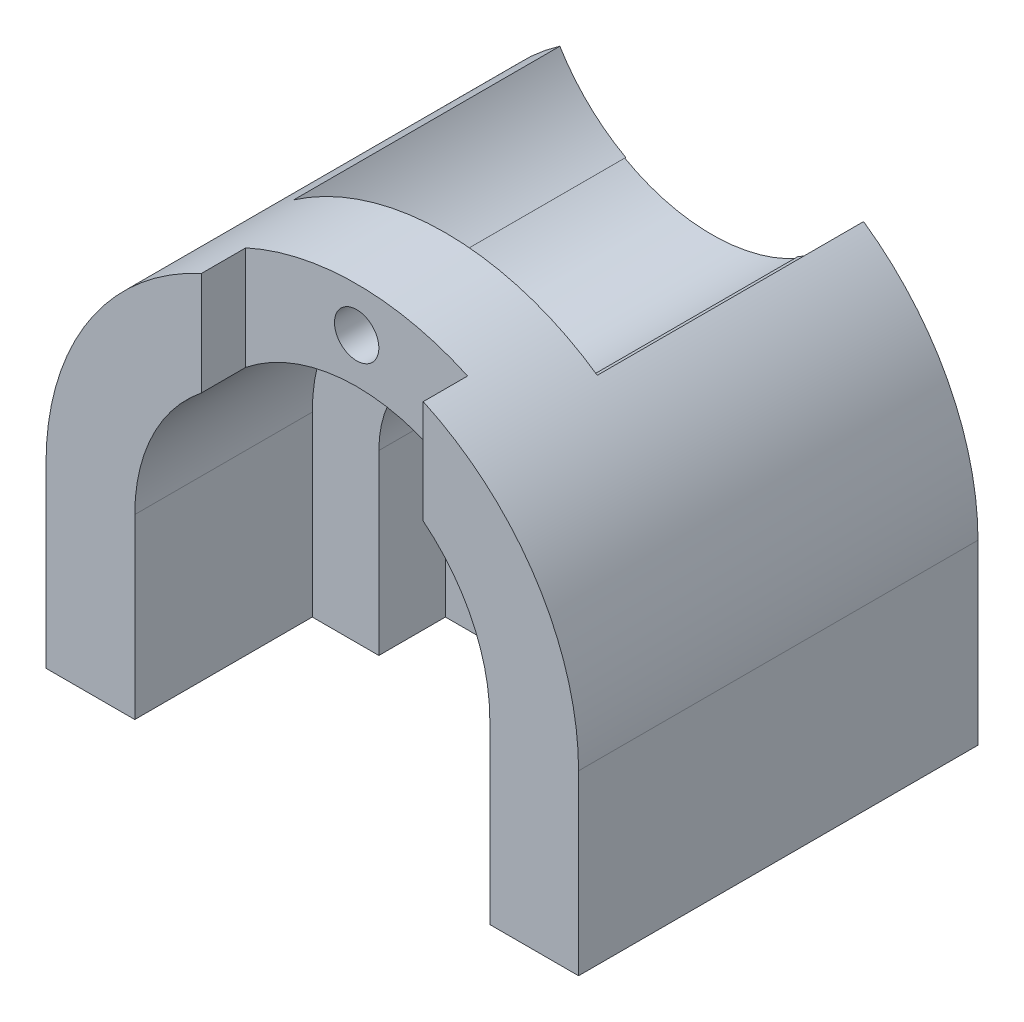
from build123d import *
from build123d.topology import SkipClean

# Parameters (mm, degrees)
BOSS_EXTRUDE1_DEPTH      = 90
SKETCH3_R                = 10
CUT_EXTRUDE2_DEPTH       = 90
SKETCH6_R                = 10
BOSS_EXTRUDE2_DEPTH      = 90
SKETCH7_R                = 5
CUT_EXTRUDE3_DEPTH       = 90
CUT_EXTRUDE4_START       = -60
CUT_EXTRUDE4_DEPTH       = 60
CUT_EXTRUDE5_START       = 60
CUT_EXTRUDE5_DEPTH       = 60
BOSS_EXTRUDE3_START      = 10
BOSS_EXTRUDE3_DEPTH      = 10
BOSS_EXTRUDE4_DEPTH      = 55
CUT_EXTRUDE6_DEPTH       = 40
CUT_EXTRUDE7_START       = -106
CUT_EXTRUDE7_DEPTH       = 106
SKETCH16_R               = 5
CUT_EXTRUDE8_DEPTH       = 106
CUT_EXTRUDE9_DEPTH       = 70
SKETCH18_R               = 5
BOSS_EXTRUDE6_DEPTH      = 15
CUT_EXTRUDE18_DEPTH      = 40
SKETCH22_W               = 40
SKETCH22_H               = 41.844000914
CUT_EXTRUDE19_DEPTH      = 20
SKETCH23_W               = 40
SKETCH23_H               = 40.367693543
CUT_EXTRUDE20_DEPTH      = 20
SKETCH25_R               = 25
BOSS_EXTRUDE7_DEPTH      = 40
SKETCH26_R               = 25
CUT_EXTRUDE21_DEPTH      = 10
CUT_EXTRUDE22_START      = -34
CUT_EXTRUDE22_DEPTH      = 34
SKETCH28_R               = 25
CUT_EXTRUDE24_DEPTH      = 60
BOSS_EXTRUDE10_START     = 15
BOSS_EXTRUDE10_DEPTH     = 15
BOSS_EXTRUDE11_DEPTH     = 30
CUT_EXTRUDE28_START      = 209.999
CUT_EXTRUDE28_DEPTH      = 209.999
BOSS_EXTRUDE12_DEPTH     = 30
SKETCH36_W               = 50
SKETCH36_H               = 10
CUT_EXTRUDE29_DEPTH      = 87
SKETCH38_R               = 5
CUT_EXTRUDE30_DEPTH      = 87
BOSS_EXTRUDE14_START     = -60
SKETCH39_R               = 10
BOSS_EXTRUDE14_DEPTH     = 60
SKETCH40_R               = 10
CUT_EXTRUDE31_DEPTH      = 40
CUT_EXTRUDE32_DEPTH      = 20
SKETCH47_W               = 40
SKETCH47_H               = 10
CUT_EXTRUDE34_DEPTH      = 65
BOSS_EXTRUDE23_DEPTH     = 20
CUT_EXTRUDE35_START      = -20
SKETCH49_R               = 10
CUT_EXTRUDE35_DEPTH      = 20
SKETCH50_R               = 25
CUT_EXTRUDE36_DEPTH      = 60
CUT_EXTRUDE39_DEPTH      = 40
CUT_EXTRUDE41_START      = 4574
CUT_EXTRUDE41_DEPTH      = 4574
BOSS_EXTRUDE24_DEPTH     = 20
CUT_EXTRUDE43_DEPTH      = 117.619037897
CUT_EXTRUDE43_DEPTH_BACK = 117.619037897
CUT_EXTRUDE47_DEPTH      = 30
CUT_EXTRUDE48_DEPTH      = 5


with BuildPart() as part:
    # Sketch1 → Boss-Extrude1 (new body)
    with BuildSketch(Plane.XY):
        with BuildLine():
            Line((-40, 0), (-40, -40))
            Line((-40, -40), (40, -40))
            Line((40, -40), (40, 0))
            ThreePointArc((40, 0), (0, 40), (-40, 0))
        make_face()
    extrude(amount=BOSS_EXTRUDE1_DEPTH)

    # Sketch3 → Cut-Extrude2 (cut)
    with BuildSketch(Plane.XY.offset(90)):
        Circle(SKETCH3_R)
    extrude(amount=-CUT_EXTRUDE2_DEPTH, mode=Mode.SUBTRACT)

    # Sketch6 → Boss-Extrude2 (add)
    with BuildSketch(Plane.XY.offset(90)):
        with BuildLine():
            Line((-60, 0), (-60, -40))
            Line((-60, -40), (60, -40))
            Line((60, -40), (60, 0))
            ThreePointArc((60, 0), (0, 60), (-60, 0))
        make_face()
        Circle(SKETCH6_R, mode=Mode.SUBTRACT)
    extrude(amount=-BOSS_EXTRUDE2_DEPTH)

    # Sketch7 → Cut-Extrude3 (cut)
    with BuildSketch(Plane.XY.offset(90)):
        with Locations((0, 50)):
            Circle(SKETCH7_R)
    extrude(amount=-CUT_EXTRUDE3_DEPTH, mode=Mode.SUBTRACT)

    # Sketch8 → Cut-Extrude4 (cut)
    with BuildSketch(Plane(origin=(0, 0, 0), x_dir=(-1, 0, 0), z_dir=(0, 0, -1)).offset(CUT_EXTRUDE4_START)):
        with BuildLine():
            ThreePointArc((34.218684477, 49.285714286), (0, 30), (-34.218684477, 49.285714286))
            ThreePointArc((-34.218684477, 49.285714286), (0, 60), (34.218684477, 49.285714286))
        make_face()
    extrude(amount=CUT_EXTRUDE4_DEPTH, mode=Mode.SUBTRACT)

    # Sketch10 → Cut-Extrude5 (cut)
    with BuildSketch(Plane.XY.offset(50).offset(CUT_EXTRUDE5_START)):
        with BuildLine():
            ThreePointArc((25, 54.543560573), (0, 60), (-25, 54.543560573))
            Line((-25, 54.543560573), (-25, 32))
            ThreePointArc((-25, 32), (0, 40.607881008), (25, 32))
            Line((25, 32), (25, 54.543560573))
        make_face()
    extrude(amount=-CUT_EXTRUDE5_DEPTH, mode=Mode.SUBTRACT)

    # Sketch12 → Boss-Extrude3 (add)
    with SkipClean():  # the faces are left unmerged after this step: merging them gives an invalid solid
        with BuildSketch(Plane.XY.offset(50).offset(BOSS_EXTRUDE3_START)):
            with BuildLine():
                ThreePointArc((25, 38.775010008), (22.557314587, 36.967174529), (19.98443144, 35.35))
                ThreePointArc((19.98443144, 35.35), (22.554498288, 33.768248503), (25, 32))
                Line((25, 32), (25, 38.775010008))
            make_face()
            with BuildLine():
                ThreePointArc((-19.98443144, 35.35), (-22.557314587, 36.967174529), (-25, 38.775010008))
                Line((-25, 38.775010008), (-25, 32))
                Line((-25, 32), (-19.98443144, 35.35))
            make_face()
        extrude(amount=-BOSS_EXTRUDE3_DEPTH)

    # Sketch13 → Boss-Extrude4 (add)
    with BuildSketch(Plane.XY.offset(90)):
        with BuildLine():
            Line((-25, 54.543560573), (-25, 32))
            ThreePointArc((-25, 32), (0, 40.607881008), (25, 32))
            Line((25, 32), (25, 54.543560573))
            ThreePointArc((25, 54.543560573), (0, 60), (-25, 54.543560573))
        make_face()
    extrude(amount=-BOSS_EXTRUDE4_DEPTH)

    # Sketch14 → Cut-Extrude6 (cut)
    with BuildSketch(Plane.XY.offset(90)):
        with BuildLine():
            Line((-25, 54.543560573), (-25, 32))
            ThreePointArc((-25, 32), (0, 40.607881008), (25, 32))
            Line((25, 32), (25, 54.543560573))
            ThreePointArc((25, 54.543560573), (0, 60), (-25, 54.543560573))
        make_face()
    extrude(amount=-CUT_EXTRUDE6_DEPTH, mode=Mode.SUBTRACT)

    # Sketch15 → Cut-Extrude7 (cut)
    with BuildSketch(Plane(origin=(0, 0, 35), x_dir=(-1, 0, 0), z_dir=(0, 0, -1)).offset(CUT_EXTRUDE7_START)):
        with BuildLine():
            ThreePointArc((-19.98443144, 35.35), (0, 40.607881008), (19.98443144, 35.35))
            ThreePointArc((19.98443144, 35.35), (0, 30), (-19.98443144, 35.35))
        make_face()
    extrude(amount=CUT_EXTRUDE7_DEPTH, mode=Mode.SUBTRACT)

    # Sketch16 → Cut-Extrude8 (cut)
    with BuildSketch(Plane.XY.offset(50)):
        with Locations((0, 50)):
            Circle(SKETCH16_R)
    extrude(amount=-CUT_EXTRUDE8_DEPTH, mode=Mode.SUBTRACT)

    # Sketch17 → Cut-Extrude9 (cut)
    with BuildSketch(Plane.XY.offset(90)):
        with BuildLine():
            Line((-25, 0), (-25, -40))
            Line((-25, -40), (25, -40))
            Line((25, -40), (25, 0))
            ThreePointArc((25, 0), (0, 25), (-25, 0))
        make_face()
    extrude(amount=-CUT_EXTRUDE9_DEPTH, mode=Mode.SUBTRACT)

    # Sketch18 → Boss-Extrude6 (add)
    with BuildSketch(Plane.XY.offset(50)):
        with Locations((0, 50)):
            Circle(SKETCH18_R)
    extrude(amount=-BOSS_EXTRUDE6_DEPTH)

    # Sketch19 → Cut-Extrude18 (cut)
    with BuildSketch(Plane.XY.offset(50)):
        with BuildLine():
            Line((-40, 0), (-40, -40))
            Line((-40, -40), (40, -40))
            Line((40, -40), (40, 0))
            ThreePointArc((40, 0), (0, 40), (-40, 0))
        make_face()
    extrude(amount=CUT_EXTRUDE18_DEPTH, mode=Mode.SUBTRACT)

    # Sketch22 → Cut-Extrude19 (cut)
    with BuildSketch(Plane(origin=(-25, 0, 0), x_dir=(0, 0, -1), z_dir=(1, 0, 0))):
        with Locations((-70, 33.621560116)):
            Rectangle(SKETCH22_W, SKETCH22_H)
    extrude(amount=CUT_EXTRUDE19_DEPTH, mode=Mode.SUBTRACT)

    # Sketch23 → Cut-Extrude20 (cut)
    with BuildSketch(Plane.ZY.offset(-25)):
        with Locations((70, 34.359713801)):
            Rectangle(SKETCH23_W, SKETCH23_H)
    extrude(amount=CUT_EXTRUDE20_DEPTH, mode=Mode.SUBTRACT)

    # Sketch27 → Cut-Extrude22 (cut)
    with SkipClean():  # the faces are left unmerged after this step: merging them gives an invalid solid
        with BuildSketch(Plane(origin=(0, 0, 35), x_dir=(-1, 0, 0), z_dir=(0, 0, -1)).offset(CUT_EXTRUDE22_START)):
            with BuildLine():
                Line((-25, 54.543560573), (-25, 38.775010008))
                ThreePointArc((-25, 38.775010008), (-22.557314587, 36.967174529), (-19.98443144, 35.35))
                ThreePointArc((-19.98443144, 35.35), (0, 40.607881008), (19.98443144, 35.35))
                ThreePointArc((19.98443144, 35.35), (22.557314587, 36.967174529), (25, 38.775010008))
                Line((25, 38.775010008), (25, 54.543560573))
                ThreePointArc((25, 54.543560573), (0, 60), (-25, 54.543560573))
            make_face()
        extrude(amount=CUT_EXTRUDE22_DEPTH, mode=Mode.SUBTRACT)

    # Sketch32 → Boss-Extrude10 (add)
    with SkipClean():  # the faces are left unmerged after this step: merging them gives an invalid solid
        with BuildSketch(Plane.XY.offset(20).offset(BOSS_EXTRUDE10_START)):
            with BuildLine():
                Line((-25, 0), (-25, -40))
                Line((-25, -40), (25, -40))
                Line((25, -40), (25, 0))
                ThreePointArc((25, 0), (0, -25), (-25, 0))
            make_face()
        extrude(amount=-BOSS_EXTRUDE10_DEPTH)

    # Sketch33 → Boss-Extrude11 (add)
    with SkipClean():  # the faces are left unmerged after this step: merging them gives an invalid solid
        with BuildSketch(Plane.XY.offset(90)):
            with BuildLine():
                Line((-25, 31.224989992), (-25, 54.543560573))
                ThreePointArc((-25, 54.543560573), (0, 60), (25, 54.543560573))
                Line((25, 54.543560573), (25, 31.224989992))
                ThreePointArc((25, 31.224989992), (0, 40), (-25, 31.224989992))
            make_face()
        extrude(amount=-BOSS_EXTRUDE11_DEPTH)

    # Sketch34 → Cut-Extrude28 (cut)
    with BuildSketch(Plane.XY.offset(50).offset(CUT_EXTRUDE28_START)):
        with BuildLine():
            Line((-25, 38.775010008), (-25, 31.224989992))
            ThreePointArc((-25, 31.224989992), (-22.262617418, 33.232151085), (-19.364916731, 35))
            ThreePointArc((-19.364916731, 35), (-22.262617418, 36.767848915), (-25, 38.775010008))
        make_face()
    extrude(amount=-CUT_EXTRUDE28_DEPTH, mode=Mode.SUBTRACT)

    # Sketch35 → Boss-Extrude12 (add)
    with SkipClean():  # the faces are left unmerged after this step: merging them gives an invalid solid
        with BuildSketch(Plane.XY.offset(90)):
            with BuildLine():
                Line((-25, 31.224989992), (-25, 38.775010008))
                ThreePointArc((-25, 38.775010008), (-22.262617418, 36.767848915), (-19.364916731, 35))
                ThreePointArc((-19.364916731, 35), (-22.262617418, 33.232151085), (-25, 31.224989992))
            make_face()
        extrude(amount=-BOSS_EXTRUDE12_DEPTH)

    # Sketch36 → Cut-Extrude29 (cut)
    with SkipClean():  # the faces are left unmerged after this step: merging them gives an invalid solid
        with BuildSketch(Plane(origin=(0, 0, 0), x_dir=(1, 0, 0), z_dir=(0, 1, 0))):
            with Locations((0, -85)):
                Rectangle(SKETCH36_W, SKETCH36_H)
        extrude(amount=CUT_EXTRUDE29_DEPTH, mode=Mode.SUBTRACT)

    # Sketch38 → Cut-Extrude30 (cut)
    with SkipClean():  # the faces are left unmerged after this step: merging them gives an invalid solid
        with BuildSketch(Plane.XY.offset(80)):
            with Locations((0, 50)):
                Circle(SKETCH38_R)
        extrude(amount=-CUT_EXTRUDE30_DEPTH, mode=Mode.SUBTRACT)

    # Sketch39 → Boss-Extrude14 (add)
    with BuildSketch(Plane(origin=(0, 0, 0), x_dir=(-1, 0, 0), z_dir=(0, 0, -1)).offset(BOSS_EXTRUDE14_START)):
        with BuildLine():
            Line((-60, 0), (-60, -40))
            Line((-60, -40), (60, -40))
            Line((60, -40), (60, 0))
            ThreePointArc((60, 0), (53.165407309, 27.810779667), (34.218684477, 49.285714286))
            ThreePointArc((34.218684477, 49.285714286), (0, 30), (-34.218684477, 49.285714286))
            ThreePointArc((-34.218684477, 49.285714286), (-53.165407309, 27.810779667), (-60, 0))
        make_face()
        Circle(SKETCH39_R, mode=Mode.SUBTRACT)
    extrude(amount=BOSS_EXTRUDE14_DEPTH)

    # Sketch40 → Cut-Extrude31 (cut)
    with BuildSketch(Plane.XY.offset(60)):
        with BuildLine():
            ThreePointArc((25, 0), (0, 25), (-25, 0))
            ThreePointArc((-25, 0), (0, -25), (25, 0))
        make_face()
        Circle(SKETCH40_R, mode=Mode.SUBTRACT)
    extrude(amount=-CUT_EXTRUDE31_DEPTH, mode=Mode.SUBTRACT)

    # Sketch41 → Cut-Extrude32 (cut)
    with BuildSketch(Plane.XY.offset(60)):
        with BuildLine():
            Line((-25, 0), (-25, -40))
            Line((-25, -40), (25, -40))
            Line((25, -40), (25, 0))
            ThreePointArc((25, 0), (0, -25), (-25, 0))
        make_face()
    extrude(amount=-CUT_EXTRUDE32_DEPTH, mode=Mode.SUBTRACT)

    # Sketch47 → Cut-Extrude34 (cut)
    with BuildSketch(Plane(origin=(0, 0, 0), x_dir=(1, 0, 0), z_dir=(0, 1, 0))):
        with Locations((0.781315523, -55)):
            Rectangle(SKETCH47_W, SKETCH47_H)
    extrude(amount=CUT_EXTRUDE34_DEPTH, mode=Mode.SUBTRACT)

    # Sketch48 → Boss-Extrude23 (add)
    with BuildSketch(Plane.XY.offset(60)):
        with BuildLine():
            Line((-40, 0), (-40, -40))
            Line((-40, -40), (40, -40))
            Line((40, -40), (40, 0))
            ThreePointArc((40, 0), (0, 40), (-40, 0))
        make_face()
    extrude(amount=BOSS_EXTRUDE23_DEPTH)

    # Sketch49 → Cut-Extrude35 (cut)
    with BuildSketch(Plane(origin=(0, 0, 60), x_dir=(-1, 0, 0), z_dir=(0, 0, -1)).offset(CUT_EXTRUDE35_START)):
        Circle(SKETCH49_R)
    extrude(amount=CUT_EXTRUDE35_DEPTH, mode=Mode.SUBTRACT)

    # Sketch50 → Cut-Extrude36 (cut)
    with BuildSketch(Plane.XY.offset(80)):
        Circle(SKETCH50_R)
    extrude(amount=-CUT_EXTRUDE36_DEPTH, mode=Mode.SUBTRACT)

    # Sketch51 → Cut-Extrude39 (cut)
    with BuildSketch(Plane.XY.offset(80)):
        with BuildLine():
            Line((-25, 0), (-25, -40))
            Line((-25, -40), (25, -40))
            Line((25, -40), (25, 0))
            ThreePointArc((25, 0), (0, -25), (-25, 0))
        make_face()
    extrude(amount=-CUT_EXTRUDE39_DEPTH, mode=Mode.SUBTRACT)

    # Sketch53 → Cut-Extrude41 (cut)
    with BuildSketch(Plane.XY.offset(50).offset(CUT_EXTRUDE41_START)):
        with BuildLine():
            Line((-19.218684477, 34.919490212), (-19.218684477, 15.988813807))
            ThreePointArc((-19.218684477, 15.988813807), (1.305368543, 24.965896999), (20.781315523, 13.897371159))
            Line((20.781315523, 13.897371159), (20.781315523, 35.821981843))
            ThreePointArc((20.781315523, 35.821981843), (0.902262009, 30.010177254), (-19.218684477, 34.919490212))
        make_face()
    extrude(amount=-CUT_EXTRUDE41_DEPTH, mode=Mode.SUBTRACT)

    # Sketch54 → Boss-Extrude24 (add)
    with BuildSketch(Plane.XY.offset(80)):
        with BuildLine():
            ThreePointArc((-25, 0), (-0.181326562, 24.999342405), (24.997369654, 0.362643585))
            Line((24.997369654, 0.362643585), (25, 39.634007744))
            Line((25, 39.634007744), (-25, 39.634007744))
            Line((-25, 39.634007744), (-25, 0))
        make_face()
    extrude(amount=-BOSS_EXTRUDE24_DEPTH)

    # Sketch55 → Cut-Extrude43 (cut, two sides: drawn at the far end of the back side and taken through both)
    with SkipClean():  # the faces are left unmerged after this step: merging them gives an invalid solid
        with BuildSketch(Plane.XY.offset(80).offset(-CUT_EXTRUDE43_DEPTH_BACK)):
            with BuildLine():
                ThreePointArc((19.68583799, 34.820508076), (0, 40), (-19.68583799, 34.820508076))
                ThreePointArc((-19.68583799, 34.820508076), (0, 29.641016151), (19.68583799, 34.820508076))
            make_face()
        extrude(amount=CUT_EXTRUDE43_DEPTH + CUT_EXTRUDE43_DEPTH_BACK, mode=Mode.SUBTRACT)

    # Sketch57 → Cut-Extrude47 (cut)
    with BuildSketch(Plane.XY.offset(80)):
        with BuildLine():
            Line((-40, 0), (-40, -40))
            Line((-40, -40), (-25, -40))
            Line((-25, -40), (-25, 0))
            ThreePointArc((-25, 0), (0, 25), (25, 0))
            Line((25, 0), (25, -40))
            Line((25, -40), (40, -40))
            Line((40, -40), (40, 0))
            ThreePointArc((40, 0), (0, 40), (-40, 0))
        make_face()
    extrude(amount=-CUT_EXTRUDE47_DEPTH, mode=Mode.SUBTRACT)

    # Sketch60 → Cut-Extrude48 (cut)
    with BuildSketch(Plane.XY.offset(40)):
        with BuildLine():
            Line((-25, 0), (-25, -40))
            Line((-25, -40), (25, -40))
            Line((25, -40), (25, 0))
            ThreePointArc((25, 0), (0, -25), (-25, 0))
        make_face()
    extrude(amount=-CUT_EXTRUDE48_DEPTH, mode=Mode.SUBTRACT)


with BuildPart() as body_2:
    # Sketch25 → Boss-Extrude7 (new body)
    with BuildSketch(Plane.XY.offset(90)):
        Circle(SKETCH25_R)
    extrude(amount=-BOSS_EXTRUDE7_DEPTH)

    # Sketch26 → Cut-Extrude21 (cut)
    with BuildSketch(Plane.XY.offset(90)):
        Circle(SKETCH26_R)
    extrude(amount=-CUT_EXTRUDE21_DEPTH, mode=Mode.SUBTRACT)

    # Sketch28 → Cut-Extrude24 (cut)
    with BuildSketch(Plane.XY.offset(80)):
        Circle(SKETCH28_R)
    extrude(amount=-CUT_EXTRUDE24_DEPTH, mode=Mode.SUBTRACT)


solid = part.part
